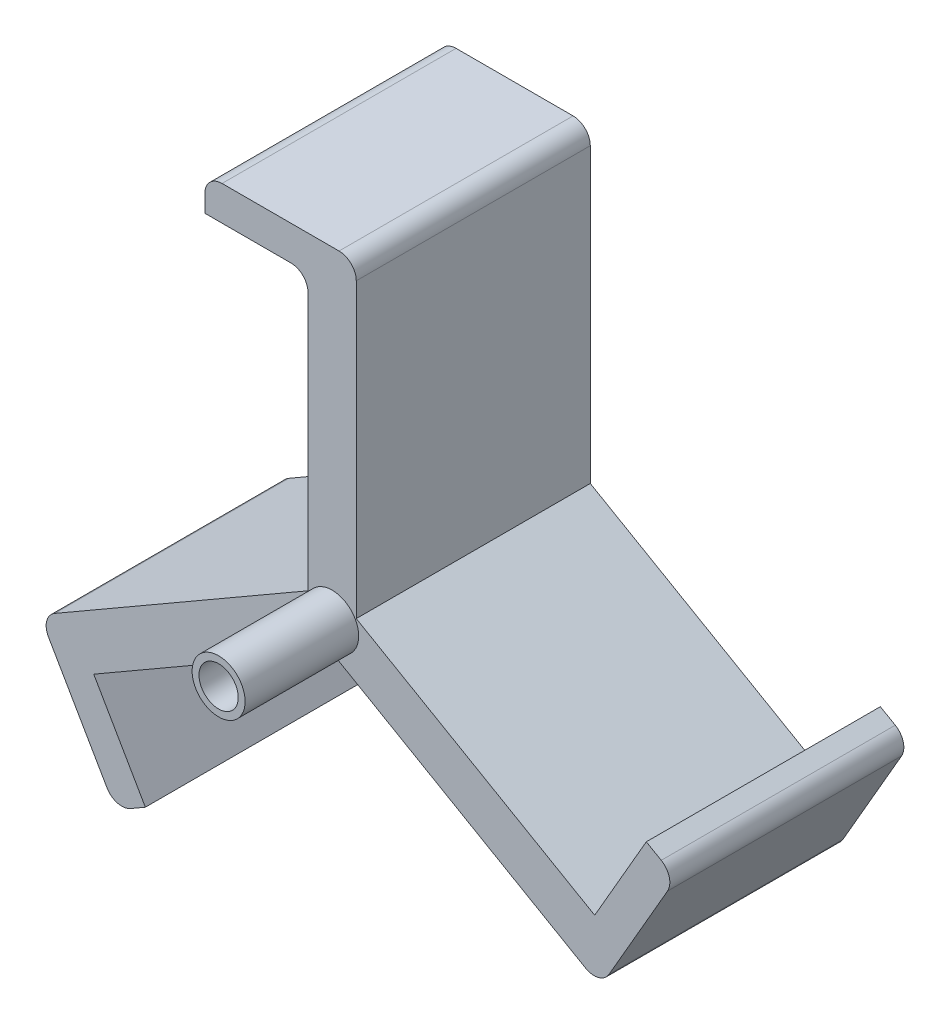
from build123d import *

# Parameters (mm, degrees)
EXTRUDE_1_DEPTH     = 34
SKETCH_4_R          = 3.85
SKETCH_4_R_2        = 2.85
EXTRUDE_2_DEPTH     = 16.5
SKETCH_5_R          = 1.85
CUT_EXTRUDE_2_DEPTH = 35
SKETCH_6_R          = 3
CUT_EXTRUDE_3_DEPTH = 4
SKETCH_7_W          = 34
SKETCH_7_H          = 5
EXTRUDE_3_DEPTH     = 15
FILLET_2_R          = 2.5
FILLET_3_R          = 2.5
FILLET_4_R          = 2.5
SKETCH_8_W          = 5
SKETCH_8_H          = 34
EXTRUDE_4_DEPTH     = 15
SKETCH_9_W          = 5
SKETCH_9_H          = 34
EXTRUDE_5_DEPTH     = 15
FILLET_5_R          = 2.5


with BuildPart() as part:
    # 草圖1 → 填料-伸長1 (new body)
    with BuildSketch(Plane.XY):
        Polygon((0.59122025, -5.441901053), (39.56236342, -27.941901053), (36.06236342, -34.00407888), (-2.90877975, -11.50407888), (-41.87992292, -34.00407888), (-45.37992292, -27.941901053), (-6.40877975, -5.441901053), (-6.40877975, 39.558098947), (0.59122025, 39.558098947), align=None)
    extrude(amount=EXTRUDE_1_DEPTH)

    # 草圖4 → 填料-伸長2 (add)
    with BuildSketch(Plane.XY.offset(34)):
        with Locations((-2.90877975, -7.462626996)):
            Circle(SKETCH_4_R)
        with Locations((-2.90877975, -7.462626996)):
            Circle(SKETCH_4_R_2, mode=Mode.SUBTRACT)
    extrude(amount=EXTRUDE_2_DEPTH)

    # 草圖5 → 除料-伸長2 (cut, through all)
    with BuildSketch(Plane.XY.offset(34)):
        with Locations((-2.90877975, -7.462626996)):
            Circle(SKETCH_5_R)
    extrude(amount=-CUT_EXTRUDE_2_DEPTH, mode=Mode.SUBTRACT)

    # 草圖6 → 除料-伸長3 (cut)
    with BuildSketch(Plane(origin=(0, 0, 0), x_dir=(-1, 0, 0), z_dir=(0, 0, -1))):
        with Locations((2.90877975, -7.462626996)):
            Circle(SKETCH_6_R)
    extrude(amount=-CUT_EXTRUDE_3_DEPTH, mode=Mode.SUBTRACT)

    # 草圖7 → 填料-伸長3 (add)
    with BuildSketch(Plane.ZY.offset(6.40877975)):
        with Locations((17, 37.058098947)):
            Rectangle(SKETCH_7_W, SKETCH_7_H)
    extrude(amount=EXTRUDE_3_DEPTH)

    # 圓角2
    fillet_2_edges = [part.edges().sort_by_distance(p)[0] for p in [
        (-21.40877975, 39.558098947, 17),
    ]]
    fillet(fillet_2_edges, radius=FILLET_2_R)

    # 圓角3
    fillet_3_edges = [part.edges().sort_by_distance(p)[0] for p in [
        (0.59122025, 39.558098947, 17),
    ]]
    fillet(fillet_3_edges, radius=FILLET_3_R)

    # 圓角4
    fillet_4_edges = [part.edges().sort_by_distance(p)[0] for p in [
        (-6.40877975, 34.558098947, 17),
    ]]
    fillet(fillet_4_edges, radius=FILLET_4_R)

    # 草圖8 → 填料-伸長4 (add)
    with BuildSketch(Plane(origin=(4.254217341, -7.368520581, 0), x_dir=(0.866025404, 0.5, 0), z_dir=(0.5, -0.866025404, 0))):
        with Locations((-50.771116598, 17)):
            Rectangle(SKETCH_8_W, SKETCH_8_H)
    extrude(amount=EXTRUDE_4_DEPTH)

    # 草圖9 → 填料-伸長5 (add)
    with BuildSketch(Plane(origin=(-2.208607216, -3.825419912, 0), x_dir=(0.866025404, -0.5, 0), z_dir=(0.5, 0.866025404, 0))):
        with Locations((45.732962282, -17)):
            Rectangle(SKETCH_9_W, SKETCH_9_H)
    extrude(amount=EXTRUDE_5_DEPTH)

    # 圓角5
    fillet_5_edges = [part.edges().sort_by_distance(p)[0] for p in [
        (36.06236342, -34.00407888, 17),
        (-45.37992292, -27.941901053, 17),
        (-34.37992292, -46.994459937, 17),
        (47.06236342, -14.951519997, 17),
    ]]
    fillet(fillet_5_edges, radius=FILLET_5_R)


solid = part.part
